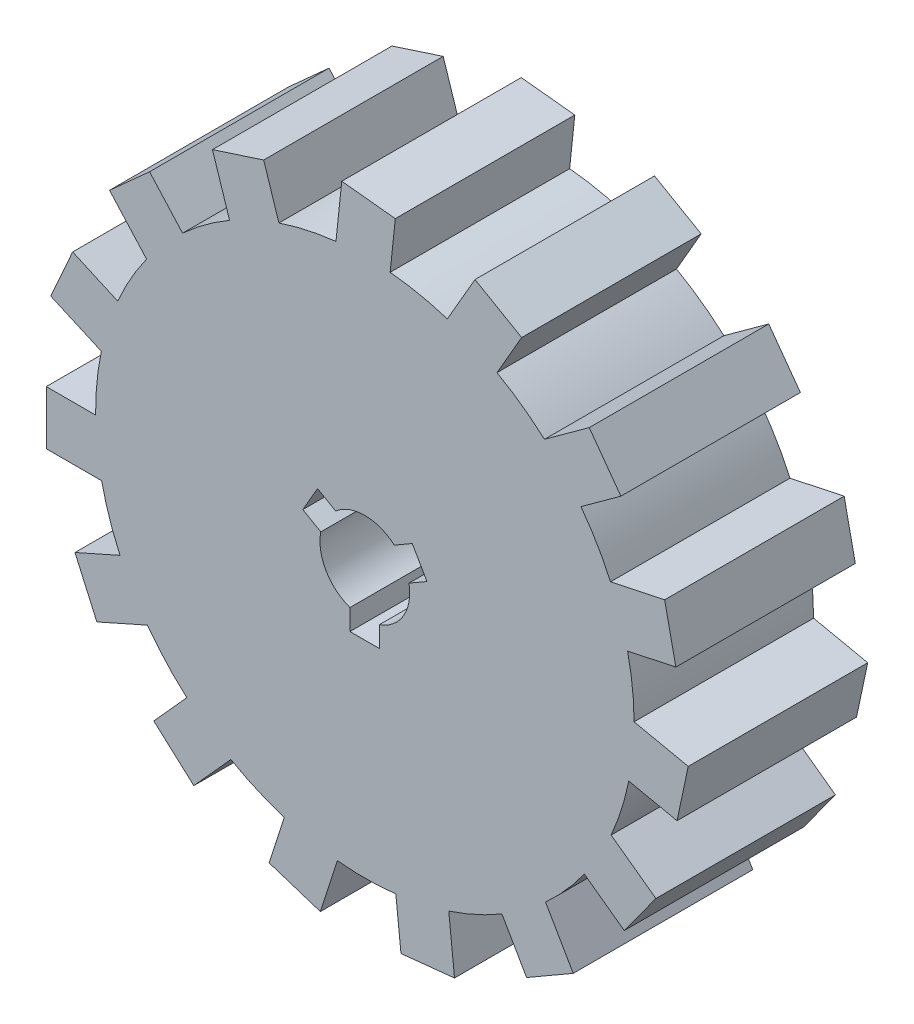
from build123d import *

# Parameters (mm, degrees)
EXTRUSION3_DEPTH = 12.7


with BuildPart() as part:
    # Sketch1 → Extrusion3 (new body)
    with BuildSketch(Plane.XY):
        with BuildLine():
            Line((21.213296498, 8.610485701), (17.381714073, 7.796057715))
            ThreePointArc((17.381714073, 7.796057715), (16.433889851, 9.634820412), (15.292273906, 11.359967376))
            Line((15.292273906, 11.359967376), (18.116572419, 13.411940358))
            Line((18.116572419, 13.411940358), (15.877110608, 16.494295106))
            Line((15.877110608, 16.494295106), (12.708043593, 14.191833146))
            ThreePointArc((12.708043593, 14.191833146), (11.094270913, 15.486111613), (9.349672368, 16.597774749))
            Line((9.349672368, 16.597774749), (11.095184843, 19.621091042))
            Line((11.095184843, 19.621091042), (7.795628055, 21.526091042))
            Line((7.795628055, 21.526091042), (5.837036927, 18.133711697))
            ThreePointArc((5.837036927, 18.133711697), (-11.299849109, 15.336750311), (-19.048930763, -0.201833587))
            Line((-19.048930763, -0.201833587), (-22.539955714, -0.201833587))
            Line((-22.539955714, -0.201833587), (-22.539955714, -4.011833587))
            Line((-22.539955714, -4.011833587), (-18.622773458, -4.011833587))
            ThreePointArc((-18.622773458, -4.011833587), (-18.077961731, -6.007478644), (-17.319971056, -7.932282309))
            Line((-17.319971056, -7.932282309), (-20.509181042, -9.352210079))
            Line((-20.509181042, -9.352210079), (-18.959514432, -12.832818272))
            Line((-18.959514432, -12.832818272), (-15.380990376, -11.239556711))
            ThreePointArc((-15.380990376, -11.239556711), (-14.071578126, -12.841074295), (-12.596231006, -14.291167358))
            Line((-12.596231006, -14.291167358), (-14.932182648, -16.885504485))
            Line((-14.932182648, -16.885504485), (-12.100800863, -19.434892096))
            Line((-12.100800863, -19.434892096), (-9.479694325, -16.523858372))
            ThreePointArc((-9.479694325, -16.523858372), (-7.632090826, -17.454331543), (-5.694488182, -18.178979739))
            Line((-5.694488182, -18.178979739), (-6.77327422, -21.499141767))
            Line((-6.77327422, -21.499141767), (-3.149748893, -22.676496515))
            Line((-3.149748893, -22.676496515), (-1.939273006, -18.951034806))
            ThreePointArc((-1.939273006, -18.951034806), (0.127054312, -19.0495763), (2.191883381, -18.923481372))
            Line((2.191883381, -18.923481372), (2.556794854, -22.395382123))
            Line((2.556794854, -22.395382123), (6.345923276, -21.997128678))
            Line((6.345923276, -21.997128678), (5.936466234, -18.101405157))
            ThreePointArc((5.936466234, -18.101405157), (7.864230606, -17.350976254), (9.699258395, -16.395941162))
            Line((9.699258395, -16.395941162), (11.44477087, -19.419257455))
            Line((11.44477087, -19.419257455), (14.744327659, -17.514257455))
            Line((14.744327659, -17.514257455), (12.785736531, -14.12187811))
            ThreePointArc((12.785736531, -14.12187811), (14.241609984, -12.652234785), (15.529543518, -11.033393772))
            Line((15.529543518, -11.033393772), (18.353842031, -13.085366754))
            Line((18.353842031, -13.085366754), (20.593303842, -10.003012005))
            Line((20.593303842, -10.003012005), (17.424236827, -7.700550045))
            ThreePointArc((17.424236827, -7.700550045), (18.156485614, -5.76580698), (18.674629484, -3.763072364))
            Line((18.674629484, -3.763072364), (22.089367164, -4.488897265))
            Line((22.089367164, -4.488897265), (22.881510706, -0.762154906))
            Line((22.881510706, -0.762154906), (19.049928281, 0.05227308))
            ThreePointArc((19.049928281, 0.05227308), (18.931939936, 2.117581232), (18.59070236, 4.157918442))
            Line((18.59070236, 4.157918442), (22.00544004, 4.883743342))
            Line((22.00544004, 4.883743342), (21.213296498, 8.610485701))
        make_face()
        with BuildLine():
            Line((-3.343536182, 3.146775418), (-2.067167627, 2.409863689))
            ThreePointArc((-2.067167627, 2.409863689), (0.010648283, 3.174982144), (2.083285387, 2.395943863))
            Line((2.083285387, 2.395943863), (3.353593084, 3.129356353))
            Line((3.353593084, 3.129356353), (4.396955543, 1.322199563))
            Line((4.396955543, 1.322199563), (3.120586988, 0.585287835))
            ThreePointArc((3.120586988, 0.585287835), (2.744291052, -1.596712756), (1.033305558, -3.00215))
            Line((1.033305558, -3.00215), (1.033305558, -4.468974981))
            Line((1.033305558, -4.468974981), (-1.053419361, -4.468974981))
            Line((-1.053419361, -4.468974981), (-1.053419361, -2.995151524))
            ThreePointArc((-1.053419361, -2.995151524), (-2.754939335, -1.578269388), (-3.116590945, 0.606206137))
            Line((-3.116590945, 0.606206137), (-4.386898641, 1.339618628))
            Line((-4.386898641, 1.339618628), (-3.343536182, 3.146775418))
        make_face(mode=Mode.SUBTRACT)
        with BuildLine():
            Line((-1.63378941, 22.835830278), (-2.043246451, 18.940106756))
            ThreePointArc((-2.043246451, 18.940106756), (-0.127054312, 19.0495763), (1.790427538, 18.965676082))
            Line((1.790427538, 18.965676082), (2.155339011, 22.437576832))
            Line((2.155339011, 22.437576832), (-1.63378941, 22.835830278))
        make_face()
        with BuildLine():
            Line((-10.780709843, 20.197047001), (-9.570233956, 16.471585292))
            ThreePointArc((-9.570233956, 16.471585292), (-7.864230606, 17.350976254), (-6.078398478, 18.054239722))
            Line((-6.078398478, 18.054239722), (-7.157184516, 21.37440175))
            Line((-7.157184516, 21.37440175), (-10.780709843, 20.197047001))
        make_face()
        with BuildLine():
            Line((-18.063547605, 14.066010814), (-15.442441067, 11.154977091))
            ThreePointArc((-15.442441067, 11.154977091), (-14.241609984, 12.652234785), (-12.896214177, 14.021061297))
            Line((-12.896214177, 14.021061297), (-15.23216582, 16.615398425))
            Line((-15.23216582, 16.615398425), (-18.063547605, 14.066010814))
        make_face()
        with BuildLine():
            Line((-22.223033883, 5.502833572), (-18.644509827, 3.909572011))
            ThreePointArc((-18.644509827, 3.909572011), (-18.156485614, 5.76580698), (-17.484157287, 7.563513996))
            Line((-17.484157287, 7.563513996), (-20.673367273, 8.983441766))
            Line((-20.673367273, 8.983441766), (-22.223033883, 5.502833572))
        make_face()
    extrude(amount=EXTRUSION3_DEPTH)


solid = part.part
